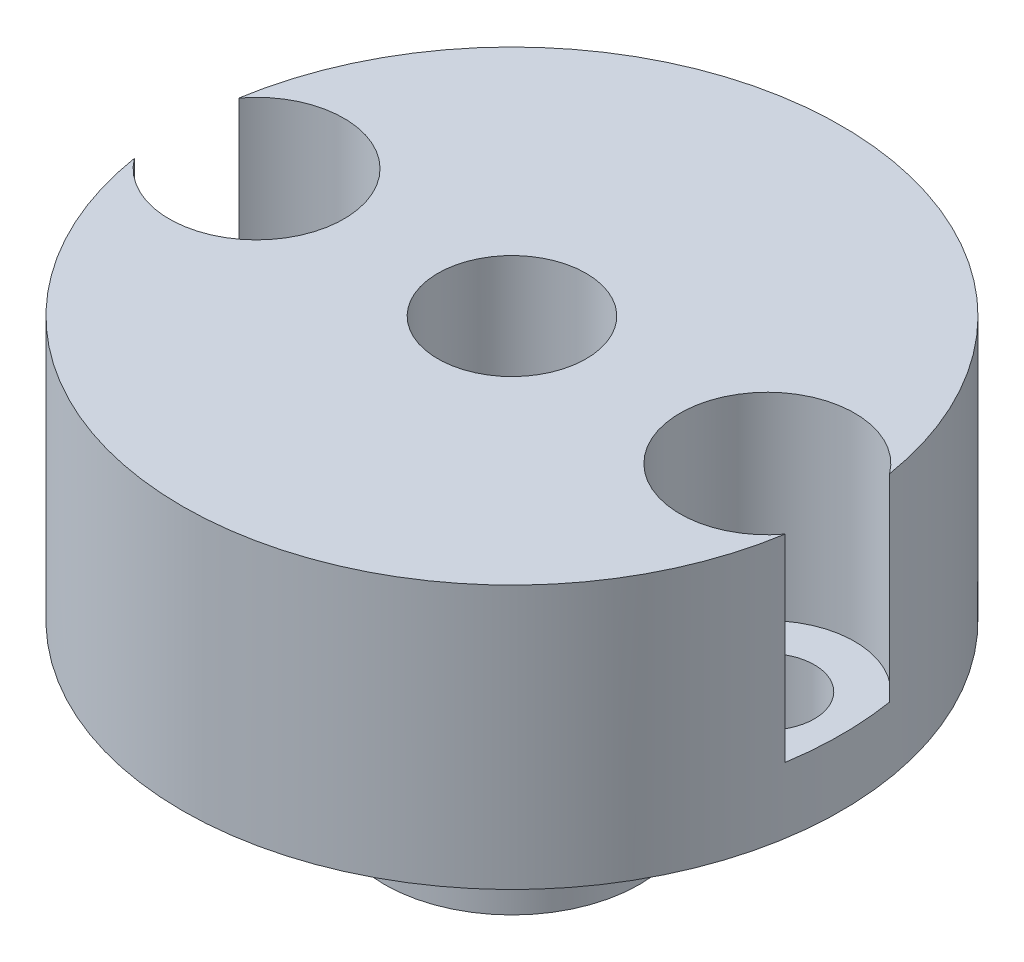
from build123d import *

# Parameters (mm, degrees)
SKETCH1_R                = 3.875
BOSS_EXTRUDE1_DEPTH      = 9
BOSS_EXTRUDE1_DEPTH_BACK = 4
SKETCH2_R                = 5.4
BOSS_EXTRUDE2_DEPTH      = 9
SKETCH7_R                = 10
BOSS_EXTRUDE4_DEPTH      = 8
CUT_EXTRUDE2_START       = -9
SKETCH3_R                = 1.425
CUT_EXTRUDE2_DEPTH       = 10
SKETCH6_R                = 2.65
CUT_EXTRUDE3_DEPTH       = 6
CIRPATTERN1_COUNT        = 2
SKETCH8_R                = 2.25
CUT_EXTRUDE4_DEPTH       = 1
CUT_EXTRUDE4_DEPTH_BACK  = 14


with BuildPart() as part:
    # Sketch1 → Boss-Extrude1 (new body, two sides)
    with BuildSketch(Plane(origin=(0, 0, 0), x_dir=(1, 0, 0), z_dir=(0, 1, 0))) as boss_extrude1_sk:
        Circle(SKETCH1_R)
    extrude(amount=BOSS_EXTRUDE1_DEPTH)
    extrude(boss_extrude1_sk.sketch, amount=-BOSS_EXTRUDE1_DEPTH_BACK)

    # Sketch2 → Boss-Extrude2 (add)
    with BuildSketch(Plane(origin=(0, 0, 0), x_dir=(1, 0, 0), z_dir=(0, 1, 0))):
        Circle(SKETCH2_R)
    extrude(amount=BOSS_EXTRUDE2_DEPTH)

    # Sketch7 → Boss-Extrude4 (add)
    with BuildSketch(Plane(origin=(0, 9, 0), x_dir=(1, 0, 0), z_dir=(0, 1, 0))):
        Circle(SKETCH7_R)
    extrude(amount=-BOSS_EXTRUDE4_DEPTH)

    # Sketch3 → Cut-Extrude2 (cut)
    with BuildSketch(Plane(origin=(0, 9, 0), x_dir=(1, 0, 0), z_dir=(0, 1, 0)).offset(CUT_EXTRUDE2_START)):
        with Locations((-7.75, 0)):
            Circle(SKETCH3_R)
    cut_extrude2 = extrude(amount=CUT_EXTRUDE2_DEPTH, mode=Mode.SUBTRACT)

    # Sketch6 → Cut-Extrude3 (cut)
    with BuildSketch(Plane(origin=(0, 9, 0), x_dir=(1, 0, 0), z_dir=(0, 1, 0))):
        with Locations((-7.75, 0)):
            Circle(SKETCH6_R)
    cut_extrude3 = extrude(amount=-CUT_EXTRUDE3_DEPTH, mode=Mode.SUBTRACT)

    # CirPattern1: Cut-Extrude2, Cut-Extrude3 ×2 about axis
    cirpattern1_axis = Axis((0, 0, 0), (0, 1, 0))
    for i in range(1, CIRPATTERN1_COUNT):
        add(cut_extrude2.rotate(cirpattern1_axis, i * 360 / CIRPATTERN1_COUNT), mode=Mode.SUBTRACT)
        add(cut_extrude3.rotate(cirpattern1_axis, i * 360 / CIRPATTERN1_COUNT), mode=Mode.SUBTRACT)

    # Sketch8 → Cut-Extrude4 (cut, two sides)
    with BuildSketch(Plane.XZ.offset(4)) as cut_extrude4_sk:
        Circle(SKETCH8_R)
    extrude(amount=CUT_EXTRUDE4_DEPTH, mode=Mode.SUBTRACT)
    extrude(cut_extrude4_sk.sketch, amount=-CUT_EXTRUDE4_DEPTH_BACK, mode=Mode.SUBTRACT)


solid = part.part
